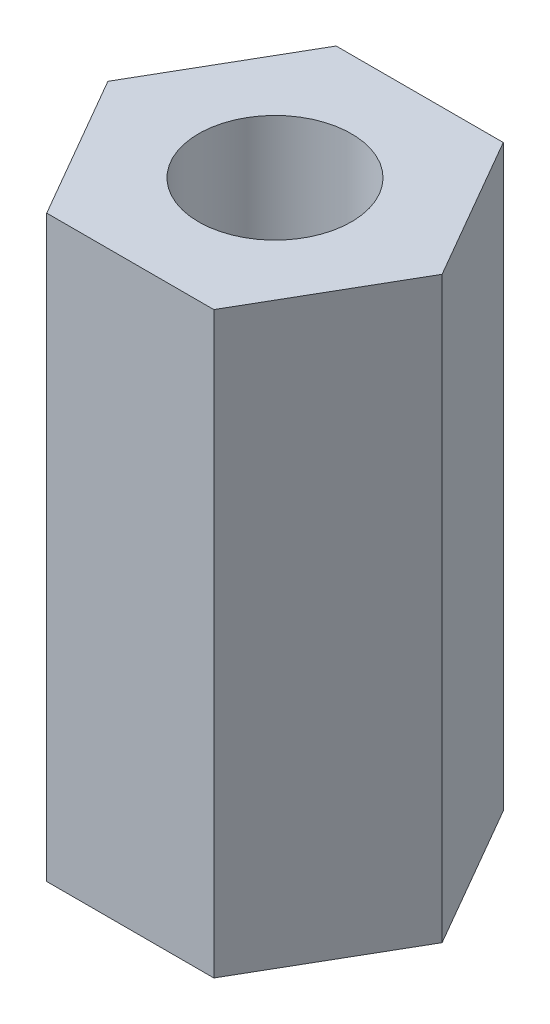
from build123d import *

# Parameters (mm, degrees)
SKETCH1_R           = 3.3528
BOSS_EXTRUDE1_DEPTH = 25.4


with BuildPart() as part:
    # Sketch1 → Boss-Extrude1 (new body)
    with BuildSketch(Plane(origin=(0, 0, 0), x_dir=(1, 0, 0), z_dir=(0, 1, 0))):
        Polygon((7.332348419, 0), (3.666174209, 6.35), (-3.666174209, 6.35), (-7.332348419, 0), (-3.666174209, -6.35), (3.666174209, -6.35), align=None)
        Circle(SKETCH1_R, mode=Mode.SUBTRACT)
    extrude(amount=BOSS_EXTRUDE1_DEPTH)


solid = part.part
